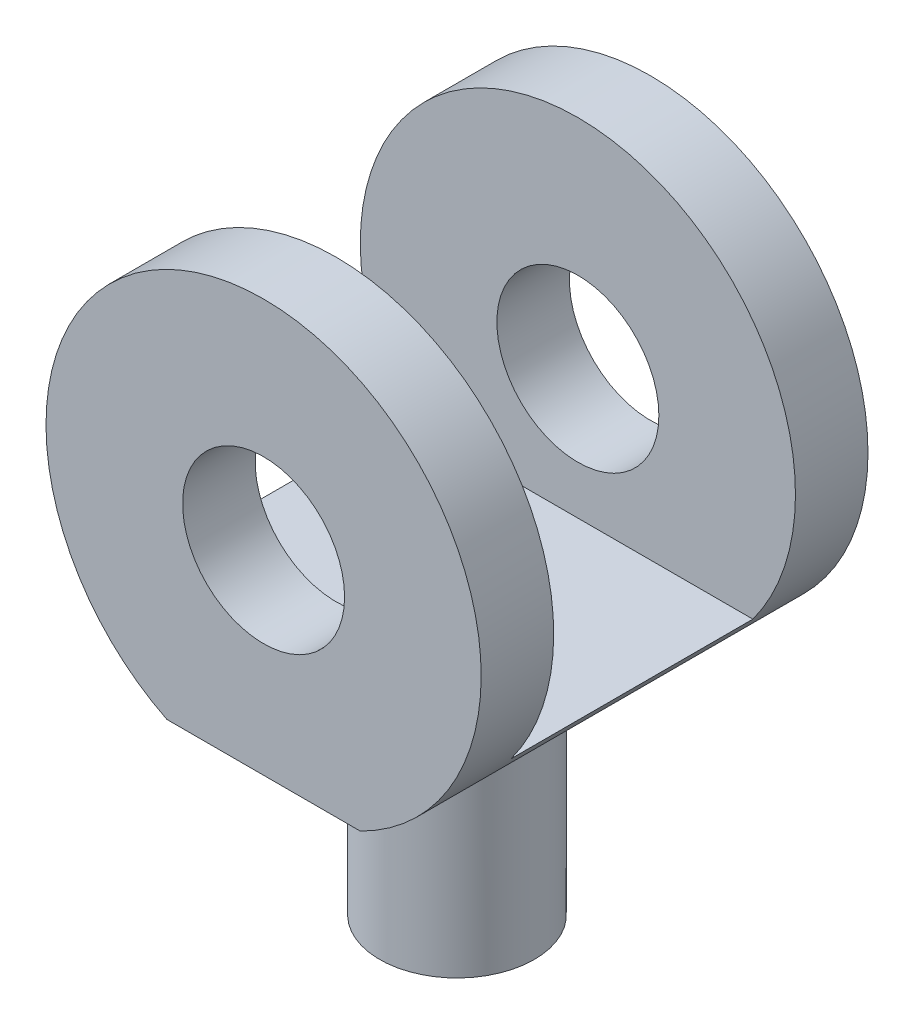
from build123d import *

# Parameters (mm, degrees)
SKETCH1_R           = 1.675
BOSS_EXTRUDE1_DEPTH = 4
CUT_EXTRUDE1_DEPTH  = 2.5
SKETCH3_R           = 1.6
BOSS_EXTRUDE2_DEPTH = 4.5
FILLET1_R           = 0.5


with BuildPart() as part:
    # Sketch1 → Boss-Extrude1 (new body, symmetric)
    with BuildSketch(Plane.XY):
        with BuildLine():
            Line((13, -4.031128874), (17, -4.031128874))
            ThreePointArc((17, -4.031128874), (15, 4.5), (13, -4.031128874))
        make_face()
        with Locations((15, 0)):
            Circle(SKETCH1_R, mode=Mode.SUBTRACT)
    extrude(amount=BOSS_EXTRUDE1_DEPTH, both=True)

    # Sketch2 → Cut-Extrude1 (cut, symmetric)
    with BuildSketch(Plane.XY):
        with BuildLine():
            Line((11.381384933, -2.675), (18.618615067, -2.675))
            ThreePointArc((18.618615067, -2.675), (15, 4.5), (11.381384933, -2.675))
        make_face()
    extrude(amount=CUT_EXTRUDE1_DEPTH, both=True, mode=Mode.SUBTRACT)

    # Sketch3 → Boss-Extrude2 (add)
    with BuildSketch(Plane.XZ.offset(4.031128874)):
        with Locations((15, 0)):
            Circle(SKETCH3_R)
    extrude(amount=BOSS_EXTRUDE2_DEPTH)

    # Fillet1
    fillet1_edges = [part.edges().sort_by_distance(p)[0] for p in [
        (13.4, -4.031128874, 0),
    ]]
    fillet(fillet1_edges, radius=FILLET1_R)


solid = part.part
